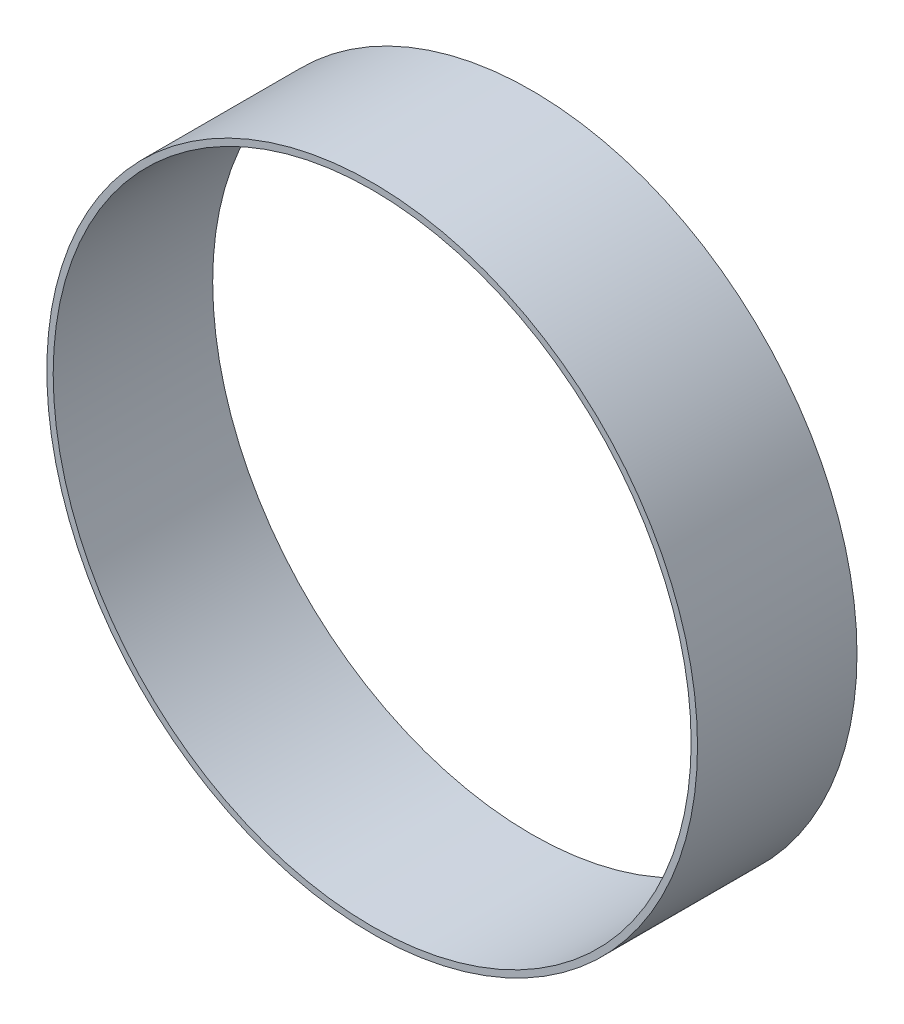
from build123d import *

# Parameters (mm, degrees)
SKETCH2_R           = 51
SKETCH2_R_2         = 50
BOSS_EXTRUDE1_DEPTH = 25


with BuildPart() as part:
    # Sketch2 → Boss-Extrude1 (new body)
    with BuildSketch(Plane.XY):
        Circle(SKETCH2_R)
        Circle(SKETCH2_R_2, mode=Mode.SUBTRACT)
    extrude(amount=BOSS_EXTRUDE1_DEPTH)


solid = part.part
